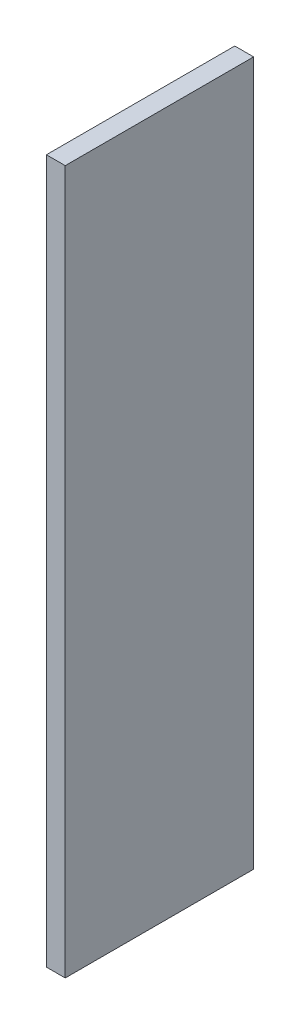
from build123d import *

# Parameters (mm, degrees)
SKETCH1_W           = 25.4
SKETCH1_H           = 94.869
BOSS_EXTRUDE1_DEPTH = 2.54


with BuildPart() as part:
    # Sketch1 → Boss-Extrude1 (new body)
    with BuildSketch(Plane(origin=(0, 0, 0), x_dir=(0, 0, -1), z_dir=(1, 0, 0))):
        with Locations((12.7, 47.4345)):
            Rectangle(SKETCH1_W, SKETCH1_H)
    extrude(amount=BOSS_EXTRUDE1_DEPTH)


solid = part.part
